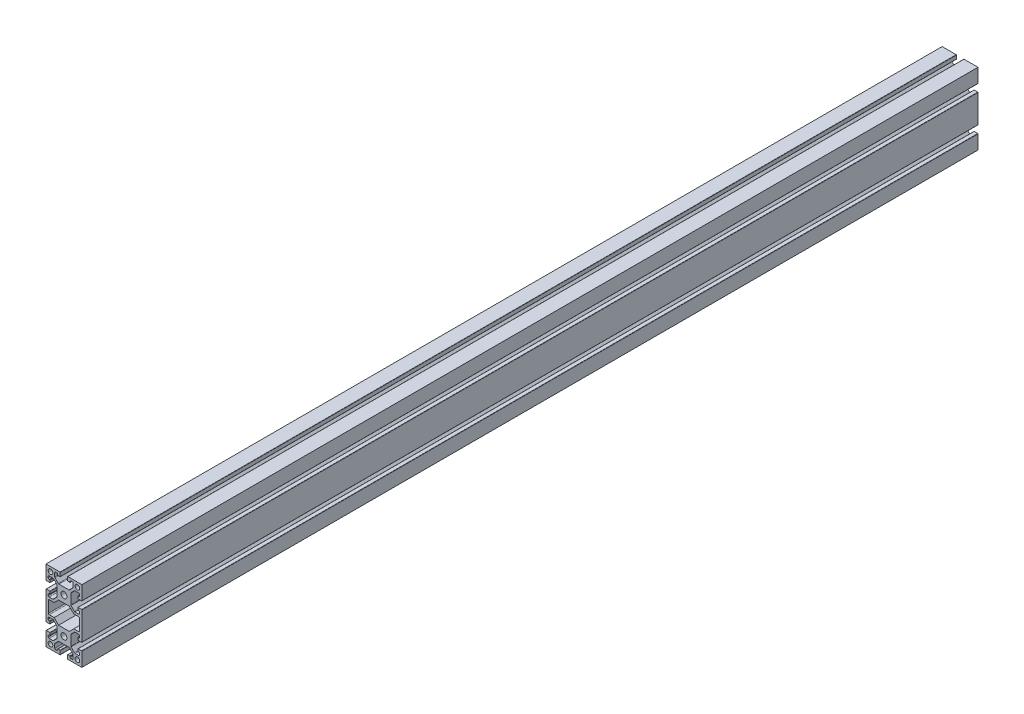
from build123d import *

# Parameters (mm, degrees)
SKETCH_2_R      = 2.6
SKETCH_2_R_2    = 3.35
EXTRUDE_1_DEPTH = 1000


with BuildPart() as part:
    # Эскиз2 → Бобышка-Вытянуть1 (new body)
    with BuildSketch(Plane.XY):
        with BuildLine():
            Line((-20, 20), (-20, 4.4))
            ThreePointArc((-20, 4.4), (-19.912132034, 4.187867966), (-19.7, 4.1))
            Line((-19.7, 4.1), (-15.8, 4.1))
            ThreePointArc((-15.8, 4.1), (-15.587867966, 4.187867966), (-15.5, 4.4))
            Line((-15.5, 4.4), (-15.5, 6.6))
            ThreePointArc((-15.5, 6.6), (-15.587867966, 6.812132034), (-15.8, 6.9))
            Line((-15.8, 6.9), (-16.5, 6.9))
            ThreePointArc((-16.5, 6.9), (-17.207106781, 7.192893219), (-17.5, 7.9))
            Line((-17.5, 7.9), (-17.5, 9.25))
            ThreePointArc((-17.5, 9.25), (-17.207106781, 9.957106781), (-16.5, 10.25))
            Line((-16.5, 10.25), (-12.364213562, 10.25))
            ThreePointArc((-12.364213562, 10.25), (-11.98153013, 10.173879533), (-11.657106781, 9.957106781))
            Line((-11.657106781, 9.957106781), (-7.992893219, 6.292893219))
            ThreePointArc((-7.992893219, 6.292893219), (-7.776120467, 5.96846987), (-7.7, 5.585786438))
            Line((-7.7, 5.585786438), (-7.7, -5.585786438))
            ThreePointArc((-7.7, -5.585786438), (-7.776120467, -5.96846987), (-7.992893219, -6.292893219))
            Line((-7.992893219, -6.292893219), (-11.657106781, -9.957106781))
            ThreePointArc((-11.657106781, -9.957106781), (-11.98153013, -10.173879533), (-12.364213562, -10.25))
            Line((-12.364213562, -10.25), (-16.5, -10.25))
            ThreePointArc((-16.5, -10.25), (-17.207106781, -9.957106781), (-17.5, -9.25))
            Line((-17.5, -9.25), (-17.5, -7.9))
            ThreePointArc((-17.5, -7.9), (-17.207106781, -7.192893219), (-16.5, -6.9))
            Line((-16.5, -6.9), (-15.8, -6.9))
            ThreePointArc((-15.8, -6.9), (-15.587867966, -6.812132034), (-15.5, -6.6))
            Line((-15.5, -6.6), (-15.5, -4.4))
            ThreePointArc((-15.5, -4.4), (-15.587867966, -4.187867966), (-15.8, -4.1))
            Line((-15.8, -4.1), (-19.7, -4.1))
            ThreePointArc((-19.7, -4.1), (-19.912132034, -4.187867966), (-20, -4.4))
            Line((-20, -4.4), (-20, -35.6))
            ThreePointArc((-20, -35.6), (-19.912132034, -35.812132034), (-19.7, -35.9))
            Line((-19.7, -35.9), (-15.8, -35.9))
            ThreePointArc((-15.8, -35.9), (-15.587867966, -35.812132034), (-15.5, -35.6))
            Line((-15.5, -35.6), (-15.5, -33.4))
            ThreePointArc((-15.5, -33.4), (-15.587867966, -33.187867966), (-15.8, -33.1))
            Line((-15.8, -33.1), (-16.5, -33.1))
            ThreePointArc((-16.5, -33.1), (-17.207106781, -32.807106781), (-17.5, -32.1))
            Line((-17.5, -32.1), (-17.5, -30.75))
            ThreePointArc((-17.5, -30.75), (-17.207106781, -30.042893219), (-16.5, -29.75))
            Line((-16.5, -29.75), (-12.364213562, -29.75))
            ThreePointArc((-12.364213562, -29.75), (-11.98153013, -29.826120467), (-11.657106781, -30.042893219))
            Line((-11.657106781, -30.042893219), (-7.992893219, -33.707106781))
            ThreePointArc((-7.992893219, -33.707106781), (-7.776120467, -34.03153013), (-7.7, -34.414213562))
            Line((-7.7, -34.414213562), (-7.7, -45.585786438))
            ThreePointArc((-7.7, -45.585786438), (-7.776120467, -45.96846987), (-7.992893219, -46.292893219))
            Line((-7.992893219, -46.292893219), (-11.657106781, -49.957106781))
            ThreePointArc((-11.657106781, -49.957106781), (-11.98153013, -50.173879533), (-12.364213562, -50.25))
            Line((-12.364213562, -50.25), (-16.5, -50.25))
            ThreePointArc((-16.5, -50.25), (-17.207106781, -49.957106781), (-17.5, -49.25))
            Line((-17.5, -49.25), (-17.5, -47.9))
            ThreePointArc((-17.5, -47.9), (-17.207106781, -47.192893219), (-16.5, -46.9))
            Line((-16.5, -46.9), (-15.8, -46.9))
            ThreePointArc((-15.8, -46.9), (-15.587867966, -46.812132034), (-15.5, -46.6))
            Line((-15.5, -46.6), (-15.5, -44.4))
            ThreePointArc((-15.5, -44.4), (-15.587867966, -44.187867966), (-15.8, -44.1))
            Line((-15.8, -44.1), (-19.7, -44.1))
            ThreePointArc((-19.7, -44.1), (-19.912132034, -44.187867966), (-20, -44.4))
            Line((-20, -44.4), (-20, -60))
            Line((-20, -60), (-4.4, -60))
            ThreePointArc((-4.4, -60), (-4.187867966, -59.912132034), (-4.1, -59.7))
            Line((-4.1, -59.7), (-4.1, -55.8))
            ThreePointArc((-4.1, -55.8), (-4.187867966, -55.587867966), (-4.4, -55.5))
            Line((-4.4, -55.5), (-6.6, -55.5))
            ThreePointArc((-6.6, -55.5), (-6.812132034, -55.587867966), (-6.9, -55.8))
            Line((-6.9, -55.8), (-6.9, -56.5))
            ThreePointArc((-6.9, -56.5), (-7.192893219, -57.207106781), (-7.9, -57.5))
            Line((-7.9, -57.5), (-9.25, -57.5))
            ThreePointArc((-9.25, -57.5), (-9.957106781, -57.207106781), (-10.25, -56.5))
            Line((-10.25, -56.5), (-10.25, -52.364213562))
            ThreePointArc((-10.25, -52.364213562), (-10.173879533, -51.98153013), (-9.957106781, -51.657106781))
            Line((-9.957106781, -51.657106781), (-6.292893219, -47.992893219))
            ThreePointArc((-6.292893219, -47.992893219), (-5.96846987, -47.776120467), (-5.585786438, -47.7))
            Line((-5.585786438, -47.7), (5.585786438, -47.7))
            ThreePointArc((5.585786438, -47.7), (5.96846987, -47.776120467), (6.292893219, -47.992893219))
            Line((6.292893219, -47.992893219), (9.957106781, -51.657106781))
            ThreePointArc((9.957106781, -51.657106781), (10.173879533, -51.98153013), (10.25, -52.364213562))
            Line((10.25, -52.364213562), (10.25, -56.5))
            ThreePointArc((10.25, -56.5), (9.957106781, -57.207106781), (9.25, -57.5))
            Line((9.25, -57.5), (7.9, -57.5))
            ThreePointArc((7.9, -57.5), (7.192893219, -57.207106781), (6.9, -56.5))
            Line((6.9, -56.5), (6.9, -55.8))
            ThreePointArc((6.9, -55.8), (6.812132034, -55.587867966), (6.6, -55.5))
            Line((6.6, -55.5), (4.4, -55.5))
            ThreePointArc((4.4, -55.5), (4.187867966, -55.587867966), (4.1, -55.8))
            Line((4.1, -55.8), (4.1, -59.7))
            ThreePointArc((4.1, -59.7), (4.187867966, -59.912132034), (4.4, -60))
            Line((4.4, -60), (20, -60))
            Line((20, -60), (20, -44.4))
            ThreePointArc((20, -44.4), (19.912132034, -44.187867966), (19.7, -44.1))
            Line((19.7, -44.1), (15.8, -44.1))
            ThreePointArc((15.8, -44.1), (15.587867966, -44.187867966), (15.5, -44.4))
            Line((15.5, -44.4), (15.5, -46.6))
            ThreePointArc((15.5, -46.6), (15.587867966, -46.812132034), (15.8, -46.9))
            Line((15.8, -46.9), (16.5, -46.9))
            ThreePointArc((16.5, -46.9), (17.207106781, -47.192893219), (17.5, -47.9))
            Line((17.5, -47.9), (17.5, -49.25))
            ThreePointArc((17.5, -49.25), (17.207106781, -49.957106781), (16.5, -50.25))
            Line((16.5, -50.25), (12.364213562, -50.25))
            ThreePointArc((12.364213562, -50.25), (11.98153013, -50.173879533), (11.657106781, -49.957106781))
            Line((11.657106781, -49.957106781), (7.992893219, -46.292893219))
            ThreePointArc((7.992893219, -46.292893219), (7.776120467, -45.96846987), (7.7, -45.585786438))
            Line((7.7, -45.585786438), (7.7, -34.414213562))
            ThreePointArc((7.7, -34.414213562), (7.776120467, -34.03153013), (7.992893219, -33.707106781))
            Line((7.992893219, -33.707106781), (11.657106781, -30.042893219))
            ThreePointArc((11.657106781, -30.042893219), (11.98153013, -29.826120467), (12.364213562, -29.75))
            Line((12.364213562, -29.75), (16.5, -29.75))
            ThreePointArc((16.5, -29.75), (17.207106781, -30.042893219), (17.5, -30.75))
            Line((17.5, -30.75), (17.5, -32.1))
            ThreePointArc((17.5, -32.1), (17.207106781, -32.807106781), (16.5, -33.1))
            Line((16.5, -33.1), (15.8, -33.1))
            ThreePointArc((15.8, -33.1), (15.587867966, -33.187867966), (15.5, -33.4))
            Line((15.5, -33.4), (15.5, -35.6))
            ThreePointArc((15.5, -35.6), (15.587867966, -35.812132034), (15.8, -35.9))
            Line((15.8, -35.9), (19.7, -35.9))
            ThreePointArc((19.7, -35.9), (19.912132034, -35.812132034), (20, -35.6))
            Line((20, -35.6), (20, -4.4))
            ThreePointArc((20, -4.4), (19.912132034, -4.187867966), (19.7, -4.1))
            Line((19.7, -4.1), (15.8, -4.1))
            ThreePointArc((15.8, -4.1), (15.587867966, -4.187867966), (15.5, -4.4))
            Line((15.5, -4.4), (15.5, -6.6))
            ThreePointArc((15.5, -6.6), (15.587867966, -6.812132034), (15.8, -6.9))
            Line((15.8, -6.9), (16.5, -6.9))
            ThreePointArc((16.5, -6.9), (17.207106781, -7.192893219), (17.5, -7.9))
            Line((17.5, -7.9), (17.5, -9.25))
            ThreePointArc((17.5, -9.25), (17.207106781, -9.957106781), (16.5, -10.25))
            Line((16.5, -10.25), (12.364213562, -10.25))
            ThreePointArc((12.364213562, -10.25), (11.98153013, -10.173879533), (11.657106781, -9.957106781))
            Line((11.657106781, -9.957106781), (7.992893219, -6.292893219))
            ThreePointArc((7.992893219, -6.292893219), (7.776120467, -5.96846987), (7.7, -5.585786438))
            Line((7.7, -5.585786438), (7.7, 5.585786438))
            ThreePointArc((7.7, 5.585786438), (7.776120467, 5.96846987), (7.992893219, 6.292893219))
            Line((7.992893219, 6.292893219), (11.657106781, 9.957106781))
            ThreePointArc((11.657106781, 9.957106781), (11.98153013, 10.173879533), (12.364213562, 10.25))
            Line((12.364213562, 10.25), (16.5, 10.25))
            ThreePointArc((16.5, 10.25), (17.207106781, 9.957106781), (17.5, 9.25))
            Line((17.5, 9.25), (17.5, 7.9))
            ThreePointArc((17.5, 7.9), (17.207106781, 7.192893219), (16.5, 6.9))
            Line((16.5, 6.9), (15.8, 6.9))
            ThreePointArc((15.8, 6.9), (15.587867966, 6.812132034), (15.5, 6.6))
            Line((15.5, 6.6), (15.5, 4.4))
            ThreePointArc((15.5, 4.4), (15.587867966, 4.187867966), (15.8, 4.1))
            Line((15.8, 4.1), (19.7, 4.1))
            ThreePointArc((19.7, 4.1), (19.912132034, 4.187867966), (20, 4.4))
            Line((20, 4.4), (20, 20))
            Line((20, 20), (4.4, 20))
            ThreePointArc((4.4, 20), (4.187867966, 19.912132034), (4.1, 19.7))
            Line((4.1, 19.7), (4.1, 15.8))
            ThreePointArc((4.1, 15.8), (4.187867966, 15.587867966), (4.4, 15.5))
            Line((4.4, 15.5), (6.6, 15.5))
            ThreePointArc((6.6, 15.5), (6.812132034, 15.587867966), (6.9, 15.8))
            Line((6.9, 15.8), (6.9, 16.5))
            ThreePointArc((6.9, 16.5), (7.192893219, 17.207106781), (7.9, 17.5))
            Line((7.9, 17.5), (9.25, 17.5))
            ThreePointArc((9.25, 17.5), (9.957106781, 17.207106781), (10.25, 16.5))
            Line((10.25, 16.5), (10.25, 12.364213562))
            ThreePointArc((10.25, 12.364213562), (10.173879533, 11.98153013), (9.957106781, 11.657106781))
            Line((9.957106781, 11.657106781), (6.292893219, 7.992893219))
            ThreePointArc((6.292893219, 7.992893219), (5.96846987, 7.776120467), (5.585786438, 7.7))
            Line((5.585786438, 7.7), (-5.585786438, 7.7))
            ThreePointArc((-5.585786438, 7.7), (-5.96846987, 7.776120467), (-6.292893219, 7.992893219))
            Line((-6.292893219, 7.992893219), (-9.957106781, 11.657106781))
            ThreePointArc((-9.957106781, 11.657106781), (-10.173879533, 11.98153013), (-10.25, 12.364213562))
            Line((-10.25, 12.364213562), (-10.25, 16.5))
            ThreePointArc((-10.25, 16.5), (-9.957106781, 17.207106781), (-9.25, 17.5))
            Line((-9.25, 17.5), (-7.9, 17.5))
            ThreePointArc((-7.9, 17.5), (-7.192893219, 17.207106781), (-6.9, 16.5))
            Line((-6.9, 16.5), (-6.9, 15.8))
            ThreePointArc((-6.9, 15.8), (-6.812132034, 15.587867966), (-6.6, 15.5))
            Line((-6.6, 15.5), (-4.4, 15.5))
            ThreePointArc((-4.4, 15.5), (-4.187867966, 15.587867966), (-4.1, 15.8))
            Line((-4.1, 15.8), (-4.1, 19.7))
            ThreePointArc((-4.1, 19.7), (-4.187867966, 19.912132034), (-4.4, 20))
            Line((-4.4, 20), (-20, 20))
        make_face()
        with BuildLine():
            ThreePointArc((17.4, -26.25), (17.107106781, -26.957106781), (16.4, -27.25))
            Line((16.4, -27.25), (10.914466094, -27.25))
            Line((10.914466094, -27.25), (6, -32.164466094))
            Line((6, -32.164466094), (-6, -32.164466094))
            Line((-6, -32.164466094), (-10.914466094, -27.25))
            Line((-10.914466094, -27.25), (-16.4, -27.25))
            ThreePointArc((-16.4, -27.25), (-17.107106781, -26.957106781), (-17.4, -26.25))
            Line((-17.4, -26.25), (-17.4, -13.75))
            ThreePointArc((-17.4, -13.75), (-17.107106781, -13.042893219), (-16.4, -12.75))
            Line((-16.4, -12.75), (-10.914466094, -12.75))
            Line((-10.914466094, -12.75), (-6, -7.835533906))
            Line((-6, -7.835533906), (6, -7.835533906))
            Line((6, -7.835533906), (10.914466094, -12.75))
            Line((10.914466094, -12.75), (16.4, -12.75))
            ThreePointArc((16.4, -12.75), (17.107106781, -13.042893219), (17.4, -13.75))
            Line((17.4, -13.75), (17.4, -26.25))
        make_face(mode=Mode.SUBTRACT)
        with Locations((-15, 15)):
            Circle(SKETCH_2_R, mode=Mode.SUBTRACT)
        Circle(SKETCH_2_R_2, mode=Mode.SUBTRACT)
        with Locations((15, 15)):
            Circle(SKETCH_2_R, mode=Mode.SUBTRACT)
        with Locations((15, -55)):
            Circle(SKETCH_2_R, mode=Mode.SUBTRACT)
        with Locations((0, -40)):
            Circle(SKETCH_2_R_2, mode=Mode.SUBTRACT)
        with Locations((-15, -55)):
            Circle(SKETCH_2_R, mode=Mode.SUBTRACT)
    extrude(amount=EXTRUDE_1_DEPTH)


solid = part.part
